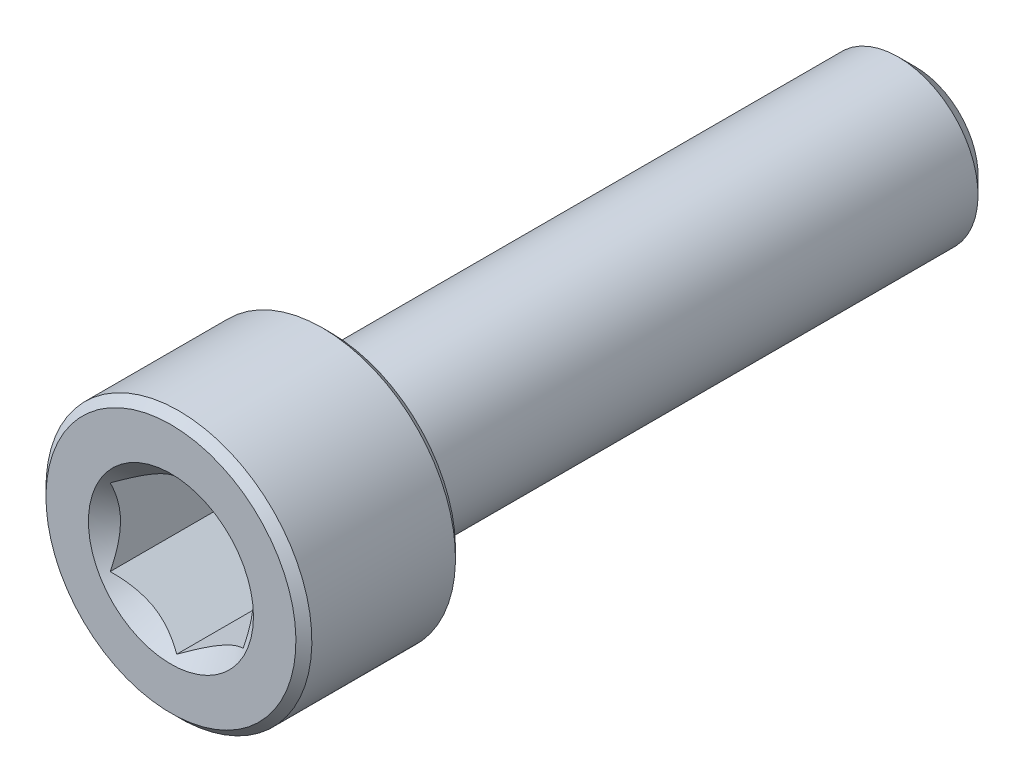
from build123d import *

# Parameters (mm, degrees)
CUT_EXTRUDE1_DEPTH = 5
SKETCH4_R          = 3.103257697
CUT_EXTRUDE2_DEPTH = 5
CUT_EXTRUDE2_DRAFT = -45


with BuildPart() as part:
    # Sketch2 → Revolve1 (revolve)
    with BuildSketch(Plane(origin=(0, 0, 0), x_dir=(0, 0, -1), z_dir=(1, 0, 0))):
        with BuildLine():
            Line((-14, 0), (-14, 4.7))
            Line((-14, 4.7), (-13.7, 5))
            Line((-13.7, 5), (-8.3, 5))
            Line((-8.3, 5), (-8, 4.7))
            Line((-8, 4.7), (-8, 3.3))
            ThreePointArc((-8, 3.3), (-7.912132034, 3.087867966), (-7.7, 3))
            Line((-7.7, 3), (13.350480947, 3))
            Line((13.350480947, 3), (14, 2.350480947))
            Line((14, 2.350480947), (14, 0))
            Line((14, 0), (-14, 0))
        make_face()
    revolve(axis=Axis((0, 0, -14), (0, 0, 1)))

    # Sketch3 → Cut-Extrude1 (cut)
    with BuildSketch(Plane.XY.offset(14)):
        Polygon((2.5, -1.443375673), (2.5, 1.443375673), (0, 2.886751346), (-2.5, 1.443375673), (-2.5, -1.443375673), (0, -2.886751346), align=None)
    extrude(amount=-CUT_EXTRUDE1_DEPTH, mode=Mode.SUBTRACT)


with BuildPart() as cut_extrude2_tool:
    # Sketch4 → Cut-Extrude2 (with draft: the straight prism first)
    with BuildSketch(Plane.XY.offset(14)):
        Circle(SKETCH4_R)
    extrude(amount=-CUT_EXTRUDE2_DEPTH)
    # Cut-Extrude2: the draft: its side faces are tilted about the plane it starts from
    cut_extrude2_sides = [cut_extrude2_tool.faces().sort_by_distance(p)[0] for p in [
        (-3.103257697, 0, 11.5),
    ]]
    draft(cut_extrude2_sides, Plane.XY.offset(14), CUT_EXTRUDE2_DRAFT)


with BuildPart() as part_1:
    add(part.part)

    # Cut-Extrude2: cut by cut_extrude2_tool
    add(cut_extrude2_tool.part, mode=Mode.SUBTRACT)


solid = part_1.part
